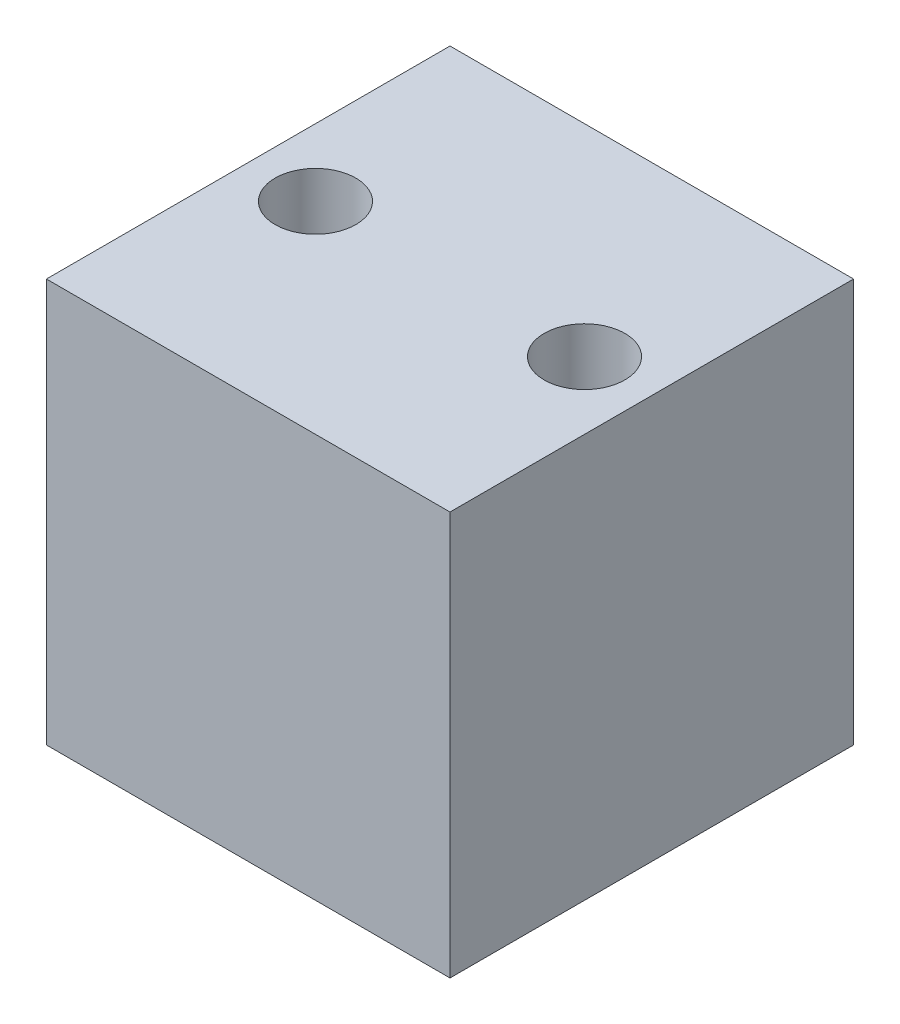
from build123d import *

# Parameters (mm, degrees)
SKETCH1_W           = 38.1
SKETCH1_H           = 38.1
SKETCH1_R           = 3.81
BOSS_EXTRUDE1_DEPTH = 38.1


with BuildPart() as part:
    # Sketch1 → Boss-Extrude1 (new body)
    with BuildSketch(Plane(origin=(0, 0, 0), x_dir=(1, 0, 0), z_dir=(0, 1, 0))):
        with Locations((-19.05, 19.05)):
            Rectangle(SKETCH1_W, SKETCH1_H)
        with Locations((-31.75, 19.05)):
            Circle(SKETCH1_R, mode=Mode.SUBTRACT)
        with Locations((-6.35, 19.05)):
            Circle(SKETCH1_R, mode=Mode.SUBTRACT)
    extrude(amount=BOSS_EXTRUDE1_DEPTH)


solid = part.part
